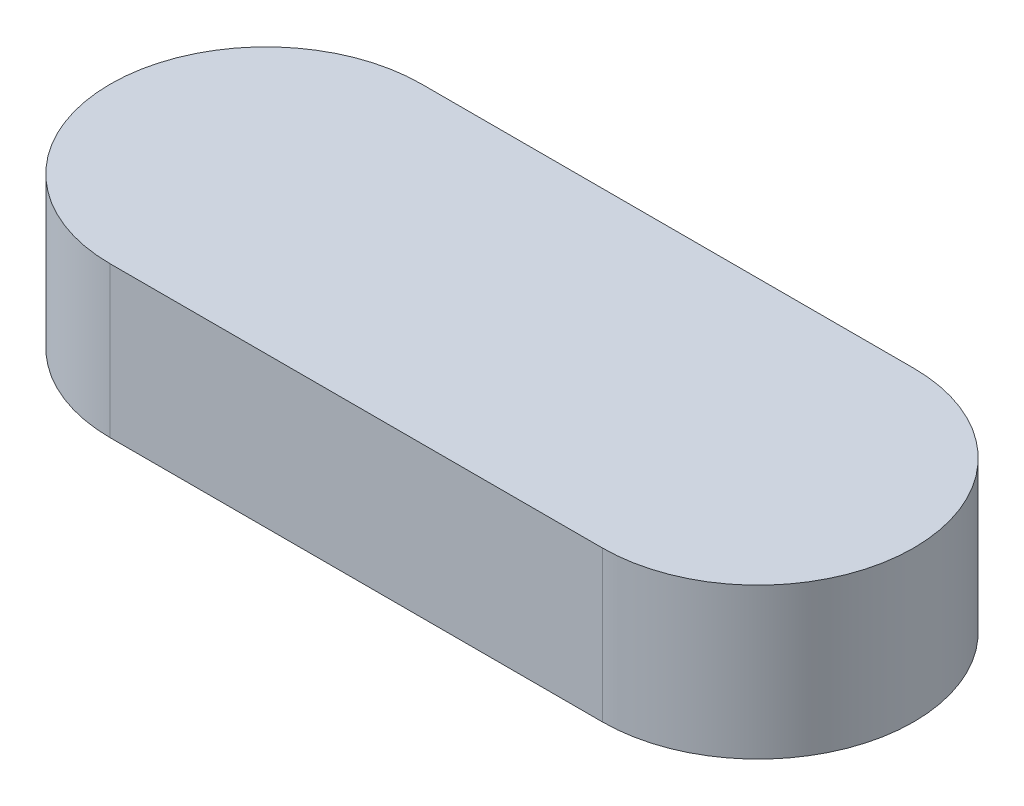
from build123d import *

# Parameters (mm, degrees)
BOSS_EXTRUDE1_DEPTH = 7.5


with BuildPart() as part:
    # Sketch2 → Boss-Extrude1 (new body)
    with BuildSketch(Plane(origin=(0, 0, 0), x_dir=(1, 0, 0), z_dir=(0, 1, 0))):
        with BuildLine():
            Line((-9.542105263, 7.75), (14.957894737, 7.75))
            ThreePointArc((14.957894737, 7.75), (22.707894737, 0), (14.957894737, -7.75))
            Line((14.957894737, -7.75), (-9.542105263, -7.75))
            ThreePointArc((-9.542105263, -7.75), (-17.292105263, 0), (-9.542105263, 7.75))
        make_face()
    extrude(amount=BOSS_EXTRUDE1_DEPTH)


solid = part.part
